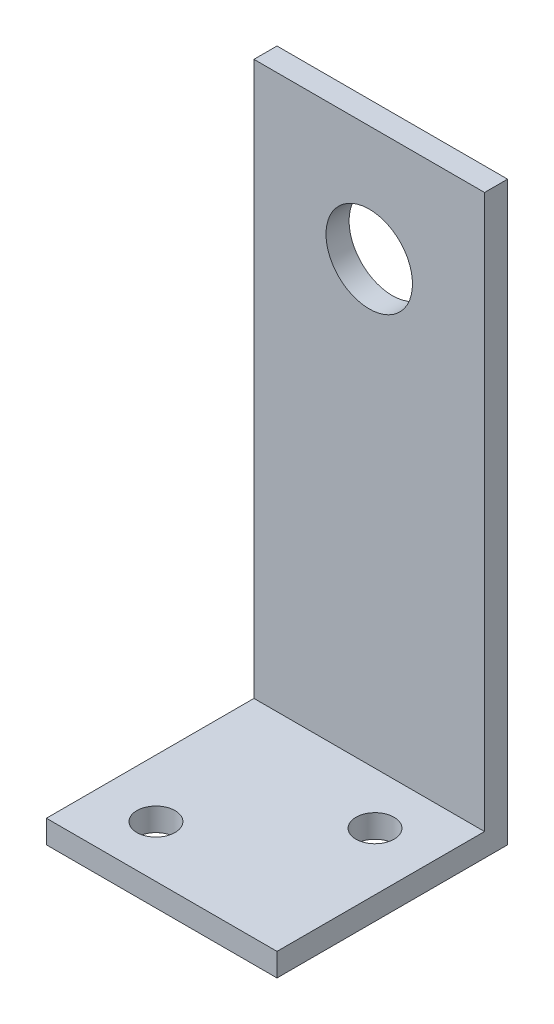
from build123d import *

# Parameters (mm, degrees)
BOSS_EXTRUDE1_DEPTH      = 12.7
BOSS_EXTRUDE1_DEPTH_BACK = 12.7
SKETCH2_R                = 4.7625
CUT_EXTRUDE1_DEPTH       = 12.7
SKETCH4_R                = 2.1
CUT_EXTRUDE2_DEPTH       = 68.250067658


with BuildPart() as part:
    # Sketch1 → Boss-Extrude1 (new, two sides: drawn at the far end of the back side and taken through both)
    with BuildSketch(Plane(origin=(0, 0, 0), x_dir=(0, 0, -1), z_dir=(1, 0, 0)).offset(-BOSS_EXTRUDE1_DEPTH_BACK)):
        Polygon((-25.4, 0), (0, 0), (0, 63.5), (-2.54, 63.5), (-2.54, 2.54), (-25.4, 2.54), align=None)
    extrude(amount=BOSS_EXTRUDE1_DEPTH + BOSS_EXTRUDE1_DEPTH_BACK)

    # Sketch2 → Cut-Extrude1 (cut)
    with BuildSketch(Plane.XY.offset(2.54)):
        with Locations((0, 50.8)):
            Circle(SKETCH2_R)
    extrude(amount=-CUT_EXTRUDE1_DEPTH, mode=Mode.SUBTRACT)

    # Sketch4 → Cut-Extrude2 (cut, through all)
    with BuildSketch(Plane(origin=(0, 2.54, 0), x_dir=(1, 0, 0), z_dir=(0, 1, 0))):
        with Locations((6.35, -8.255)):
            Circle(SKETCH4_R)
        with Locations((-6.35, -19.685)):
            Circle(SKETCH4_R)
    extrude(amount=-CUT_EXTRUDE2_DEPTH, mode=Mode.SUBTRACT)


solid = part.part
